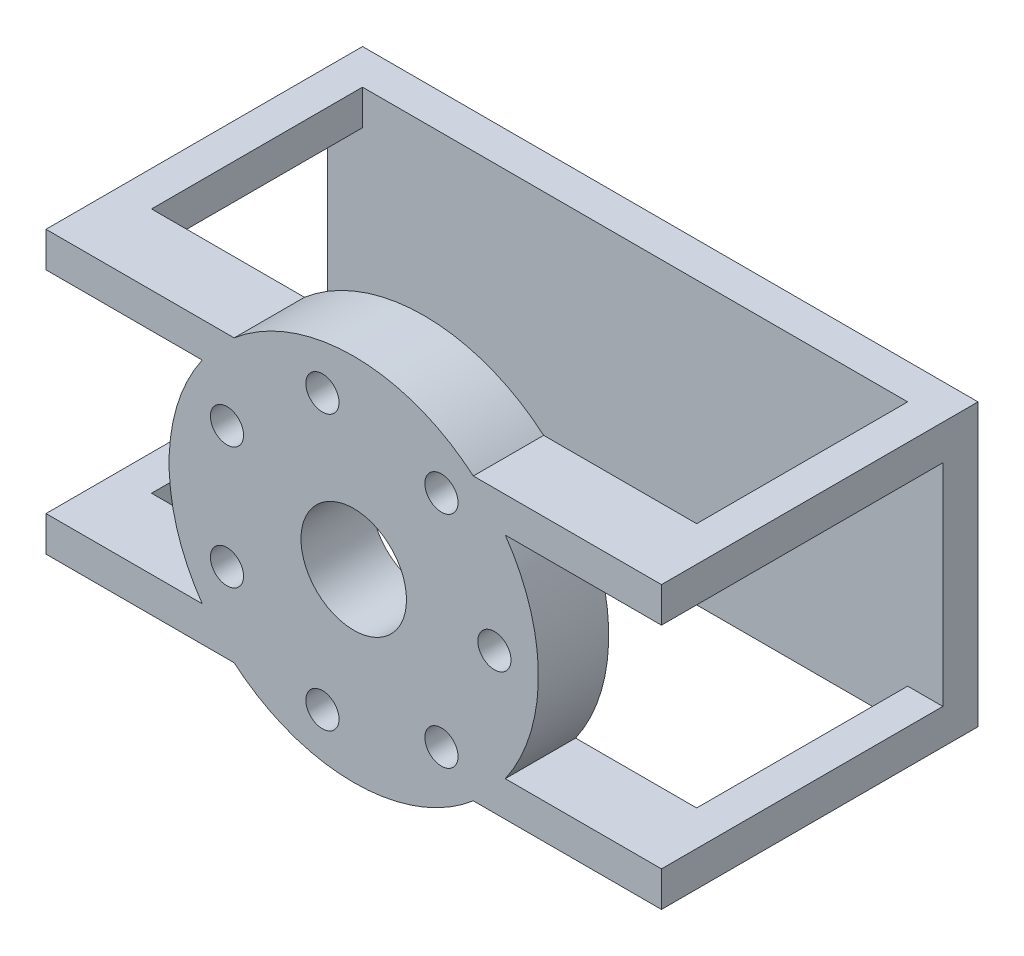
from build123d import *

# Parameters (mm, degrees)
SKETCH1_W           = 175
SKETCH1_H           = 90
BOSS_EXTRUDE1_DEPTH = 80
SKETCH2_W           = 155
SKETCH2_H           = 60
CUT_EXTRUDE1_DEPTH  = 80
SKETCH3_W           = 60
SKETCH3_H           = 60
CUT_EXTRUDE2_DEPTH  = 176
SKETCH4_R           = 52.5
BOSS_EXTRUDE3_DEPTH = 20
CUT_EXTRUDE3_DEPTH  = 20
SKETCH6_R           = 4.715207805
CUT_EXTRUDE4_DEPTH  = 20
CIRPATTERN1_COUNT   = 7
SKETCH7_R           = 15
CUT_EXTRUDE5_DEPTH  = 20


with BuildPart() as part:
    # Sketch1 → Boss-Extrude1 (new body)
    with BuildSketch(Plane(origin=(0, 0, 0), x_dir=(1, 0, 0), z_dir=(0, 1, 0))):
        Rectangle(SKETCH1_W, SKETCH1_H)
    extrude(amount=BOSS_EXTRUDE1_DEPTH)

    # Sketch2 → Cut-Extrude1 (cut)
    with BuildSketch(Plane(origin=(0, 80, 0), x_dir=(1, 0, 0), z_dir=(0, 1, 0))):
        with Locations((0, 5)):
            Rectangle(SKETCH2_W, SKETCH2_H)
    extrude(amount=-CUT_EXTRUDE1_DEPTH, mode=Mode.SUBTRACT)

    # Sketch3 → Cut-Extrude2 (cut, through all)
    with BuildSketch(Plane(origin=(87.5, 0, 0), x_dir=(0, 0, -1), z_dir=(1, 0, 0))):
        with Locations((5, 40)):
            Rectangle(SKETCH3_W, SKETCH3_H)
    extrude(amount=-CUT_EXTRUDE2_DEPTH, mode=Mode.SUBTRACT)

    # Sketch4 → Boss-Extrude3 (add)
    with BuildSketch(Plane.XY.offset(45)):
        with Locations((0, 40)):
            Circle(SKETCH4_R)
    extrude(amount=-BOSS_EXTRUDE3_DEPTH)

    # Sketch5 → Cut-Extrude3 (cut)
    with BuildSketch(Plane.XY.offset(45)):
        with BuildLine():
            Line((87.5, 70), (43.084219849, 70))
            ThreePointArc((43.084219849, 70), (52.5, 40), (43.084219849, 10))
            Line((43.084219849, 10), (87.5, 10))
            Line((87.5, 10), (87.5, 70))
        make_face()
        with BuildLine():
            Line((-43.084219849, 70), (-87.5, 70))
            Line((-87.5, 70), (-87.5, 10))
            Line((-87.5, 10), (-43.084219849, 10))
            ThreePointArc((-43.084219849, 10), (-52.5, 40), (-43.084219849, 70))
        make_face()
    extrude(amount=-CUT_EXTRUDE3_DEPTH, mode=Mode.SUBTRACT)

    # Sketch6 → Cut-Extrude4 (cut)
    with BuildSketch(Plane.XY.offset(45)):
        with Locations((40, 40)):
            Circle(SKETCH6_R)
    cut_extrude4 = extrude(amount=-CUT_EXTRUDE4_DEPTH, mode=Mode.SUBTRACT)

    # CirPattern1: Cut-Extrude4 ×7 about axis
    cirpattern1_axis = Axis((0, 40, 0), (0, 0, 1))
    for i in range(1, CIRPATTERN1_COUNT):
        add(cut_extrude4.rotate(cirpattern1_axis, i * 360 / CIRPATTERN1_COUNT), mode=Mode.SUBTRACT)

    # Sketch7 → Cut-Extrude5 (cut)
    with BuildSketch(Plane.XY.offset(45)):
        with Locations((0, 40)):
            Circle(SKETCH7_R)
    extrude(amount=-CUT_EXTRUDE5_DEPTH, mode=Mode.SUBTRACT)


solid = part.part
